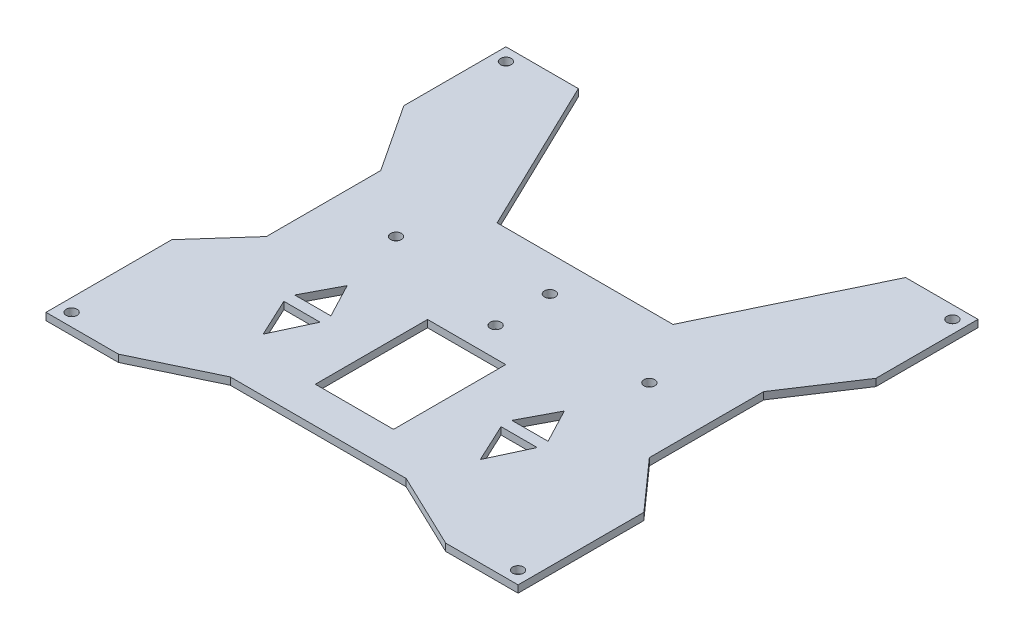
from build123d import *

# Parameters (mm, degrees)
SKETCH1_W           = 130.431067812
SKETCH1_H           = 127.071067812
SKETCH1_R           = 1.5
BOSS_EXTRUDE1_DEPTH = 2
CUT_EXTRUDE2_DEPTH  = 2
CUT_EXTRUDE3_DEPTH  = 2
SKETCH5_W           = 21.6
SKETCH5_H           = 31
CUT_EXTRUDE4_DEPTH  = 10
SKETCH6_R           = 1.5
CUT_EXTRUDE5_DEPTH  = 10
CUT_EXTRUDE6_DEPTH  = 10
CUT_EXTRUDE7_DEPTH  = 10


with BuildPart() as part:
    # Sketch1 → Boss-Extrude1 (new body)
    with BuildSketch(Plane(origin=(0, 0, 0), x_dir=(1, 0, 0), z_dir=(0, 1, 0))):
        with Locations((61.68, -60)):
            Rectangle(SKETCH1_W, SKETCH1_H)
        with Locations((0, -120)):
            Circle(SKETCH1_R, mode=Mode.SUBTRACT)
        with Locations((123.36, -120)):
            Circle(SKETCH1_R, mode=Mode.SUBTRACT)
        with Locations((123.36, 0)):
            Circle(SKETCH1_R, mode=Mode.SUBTRACT)
        Circle(SKETCH1_R, mode=Mode.SUBTRACT)
    extrude(amount=BOSS_EXTRUDE1_DEPTH)

    # Sketch3 → Cut-Extrude2 (cut)
    with BuildSketch(Plane(origin=(0, 2, 0), x_dir=(1, 0, 0), z_dir=(0, 1, 0))):
        Polygon((16.464466094, 3.535533906), (106.895533906, 3.535533906), (85.98014536, -39.812186932), (37.37985464, -39.812186932), align=None)
    extrude(amount=-CUT_EXTRUDE2_DEPTH, mode=Mode.SUBTRACT)

    # Sketch4 → Cut-Extrude3 (cut)
    with BuildSketch(Plane(origin=(0, 2, 0), x_dir=(1, 0, 0), z_dir=(0, 1, 0))):
        Polygon((85.98014536, -113.535533906), (37.37985464, -113.535533906), (16.464466094, -123.535533906), (106.895533906, -123.535533906), align=None)
    extrude(amount=-CUT_EXTRUDE3_DEPTH, mode=Mode.SUBTRACT)

    # Sketch5 → Cut-Extrude4 (cut)
    with BuildSketch(Plane(origin=(0, 2, 0), x_dir=(1, 0, 0), z_dir=(0, 1, 0))):
        with Locations((61.68, -88.035533906)):
            Rectangle(SKETCH5_W, SKETCH5_H)
    extrude(amount=-CUT_EXTRUDE4_DEPTH, mode=Mode.SUBTRACT)

    # Sketch6 → Cut-Extrude5 (cut)
    with BuildSketch(Plane(origin=(0, 2, 0), x_dir=(1, 0, 0), z_dir=(0, 1, 0))):
        with Locations((61.68, -64.535533906)):
            Circle(SKETCH6_R)
        with Locations((61.68, -49.535533906)):
            Circle(SKETCH6_R)
        with Locations((26.68, -57.035533906)):
            Circle(SKETCH6_R)
        with Locations((96.68, -57.035533906)):
            Circle(SKETCH6_R)
    extrude(amount=-CUT_EXTRUDE5_DEPTH, mode=Mode.SUBTRACT)

    # Sketch7 → Cut-Extrude6 (cut)
    with BuildSketch(Plane(origin=(0, 2, 0), x_dir=(1, 0, 0), z_dir=(0, 1, 0))):
        Polygon((31.68, -98.75817479), (36.68, -88.035533906), (31.68, -88.035533906), (26.68, -88.035533906), align=None)
        Polygon((36.68, -85.035533906), (26.68, -85.035533906), (31.68, -75.537485709), align=None)
        Polygon((86.68, -88.035533906), (91.68, -88.035533906), (96.68, -88.035533906), (91.68, -98.75817479), align=None)
        Polygon((86.68, -85.035533906), (91.68, -75.537485709), (96.68, -85.035533906), align=None)
    extrude(amount=-CUT_EXTRUDE6_DEPTH, mode=Mode.SUBTRACT)

    # Sketch8 → Cut-Extrude7 (cut)
    with BuildSketch(Plane(origin=(0, 2, 0), x_dir=(1, 0, 0), z_dir=(0, 1, 0))):
        Polygon((8.780452794, -60), (8.780452794, -43.363746638), (-3.535533906, -24.671327131), (-3.535533906, -88.786326042), (8.780452794, -74.953935606), align=None)
        Polygon((114.579547206, -43.363746638), (126.895533906, -24.671327131), (126.895533906, -88.786326042), (114.579547206, -74.953935606), (114.579547206, -60), align=None)
    extrude(amount=-CUT_EXTRUDE7_DEPTH, mode=Mode.SUBTRACT)


solid = part.part
